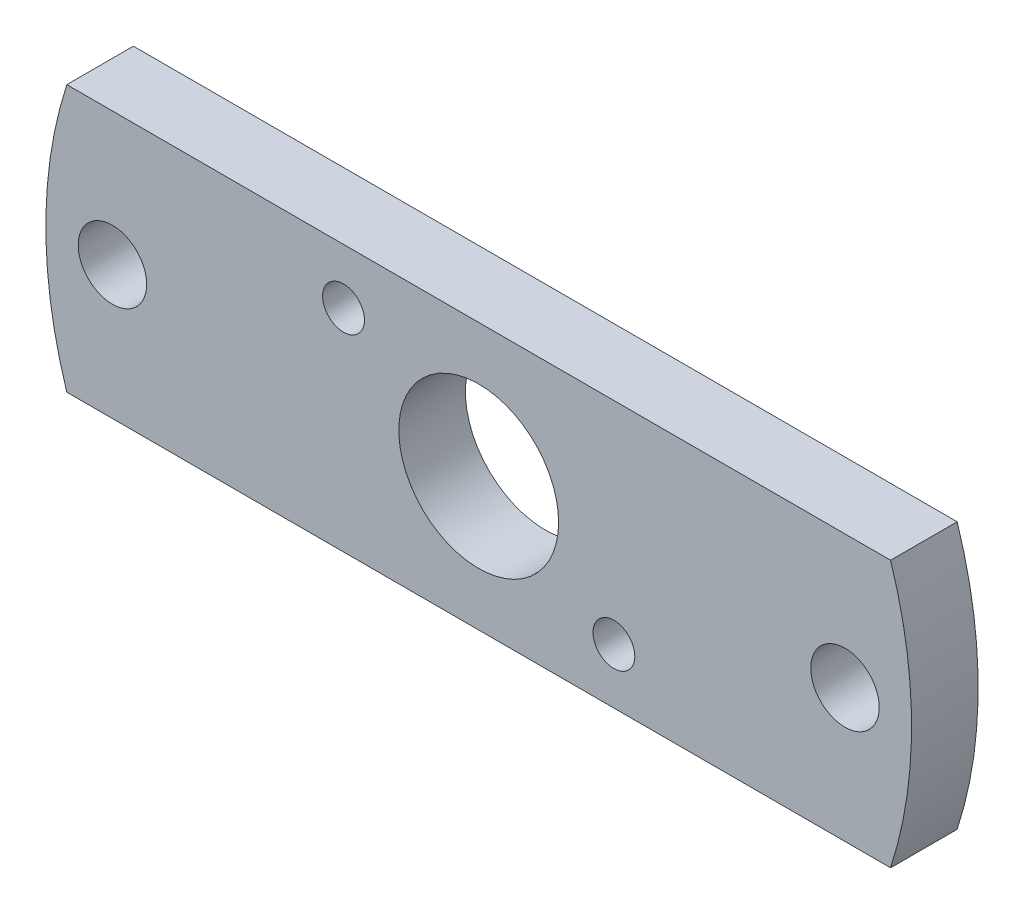
from build123d import *

# Parameters (mm, degrees)
SKETCH1_R             = 3.81
BOSS_EXTRUDE1_DEPTH   = 3.175
F_4_CLEARANCE_HOLE1_D = 3.2639
F_3_48_TAPPED_HOLE1_D = 1.9939


with BuildPart() as part:
    # Sketch1 → Boss-Extrude1 (new body)
    with BuildSketch(Plane.XY):
        with BuildLine():
            Line((-19.636290542, 6.35), (19.636290542, 6.35))
            ThreePointArc((19.636290542, 6.35), (20.6375, 0), (19.636290542, -6.35))
            Line((19.636290542, -6.35), (-19.636290542, -6.35))
            ThreePointArc((-19.636290542, -6.35), (-20.6375, 0), (-19.636290542, 6.35))
        make_face()
        Circle(SKETCH1_R, mode=Mode.SUBTRACT)
    extrude(amount=BOSS_EXTRUDE1_DEPTH)

    # #4 Clearance Hole1 (through all)
    with Locations(Plane.XY.offset(3.175)):
        with Locations((-17.4625, 0), (17.4625, 0)):
            Hole(F_4_CLEARANCE_HOLE1_D / 2)

    # #3-48 Tapped Hole1 (through all)
    with Locations(Plane.XY.offset(3.175)):
        with Locations((-6.44513426, 3.7211), (6.44513426, -3.7211)):
            Hole(F_3_48_TAPPED_HOLE1_D / 2)


solid = part.part
